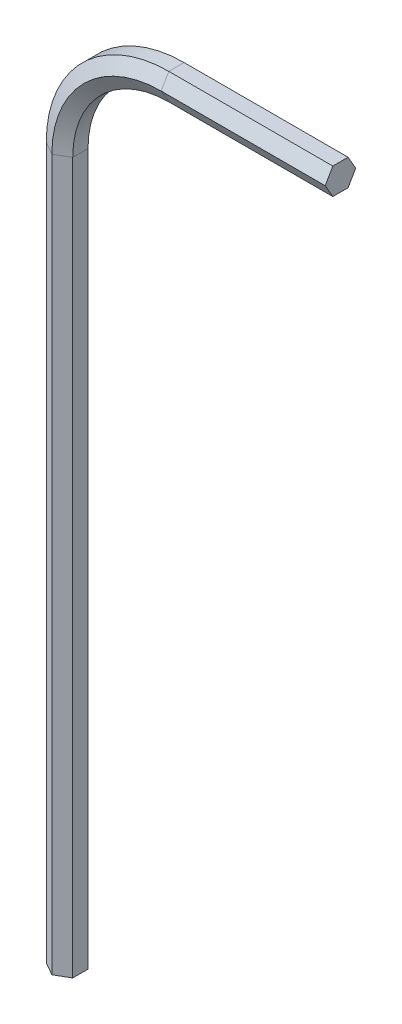
from build123d import *


with BuildPart() as part:
    # Sweep1: sweep along a path in Sketch4
    with BuildLine(Plane.XY) as sweep1_path:
        Line((0, 0), (0, 40.3))
        ThreePointArc((0, 40.3), (1.815937957, 44.684062043), (6.2, 46.5))
        Line((6.2, 46.5), (15.5, 46.5))
    # Sketch3 → Sweep1 (sweep)
    with BuildSketch(Plane(origin=(0, 0, 0), x_dir=(1, 0, 0), z_dir=(0, 1, 0))):
        Polygon((0, 0.866025404), (-0.75, 0.433012702), (-0.75, -0.433012702), (0, -0.866025404), (0.75, -0.433012702), (0.75, 0.433012702), align=None)
    sweep(path=sweep1_path.line)


solid = part.part
